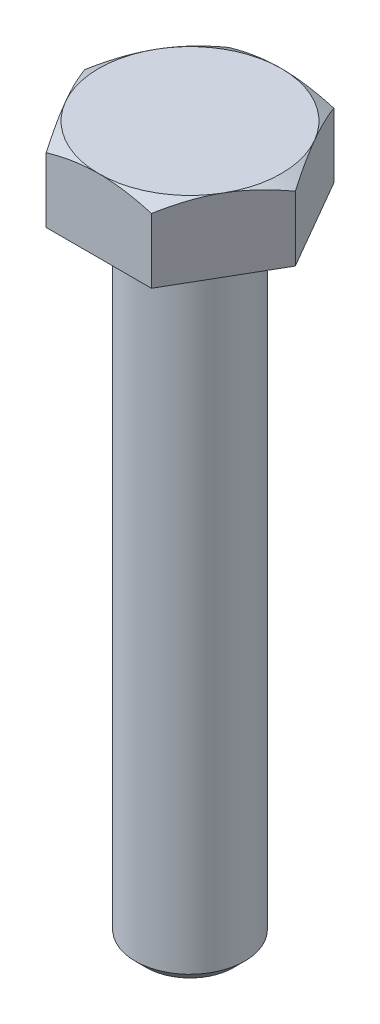
from build123d import *

# Parameters (mm, degrees)
ESQUISSE2_R             = 3
BASE_EXTRUSION_DEPTH    = 35
CHANFREIN1_SIZE         = 0.6
ESQUISSE6_OUTSIDE_W     = 24.908
ESQUISSE6_OUTSIDE_H     = 24.908
ENL_V_MAT_EXTRU_1_DEPTH = 4


with BuildPart() as part:
    # Esquisse2 → Base-Extrusion (new body)
    with BuildSketch(Plane(origin=(0, 0, 0), x_dir=(1, 0, 0), z_dir=(0, 1, 0))):
        with Locations(Location((0, 0, 0), (0, 0, 270))):  # turned: the seam where the file's is
            Circle(ESQUISSE2_R)
    extrude(amount=-BASE_EXTRUSION_DEPTH)

    # Chanfrein1
    chanfrein1_edges = [part.edges().sort_by_distance(p)[0] for p in [
        (0, -35, -3),
    ]]
    chamfer(chanfrein1_edges, length=CHANFREIN1_SIZE)

    # Esquisse5 → Boss.-Révol.1 (revolve)
    with BuildSketch(Plane.XY, mode=Mode.PRIVATE) as boss_r_vol_1_sk:
        Polygon((0, 0), (7.071067812, 0), (7.071067812, 2.804268441), (5, 4), (0, 4), align=None)
    revolve(boss_r_vol_1_sk.sketch.rotate(Axis((0, 4, 0), (0, -1, 0)), 90), axis=Axis((0, 4, 0), (0, -1, 0)))  # turned: the seam where the file's is

    # Esquisse6 outside → Enlèv. mat.-Extru.1 (cut)
    with BuildSketch(Plane.XZ):
        Rectangle(ESQUISSE6_OUTSIDE_W, ESQUISSE6_OUTSIDE_H)
        Polygon((-2.886751346, -5), (2.886751346, -5), (5.773502692, 0), (2.886751346, 5), (-2.886751346, 5), (-5.773502692, 0), align=None, mode=Mode.SUBTRACT)
    extrude(amount=-ENL_V_MAT_EXTRU_1_DEPTH, mode=Mode.SUBTRACT)


solid = part.part
